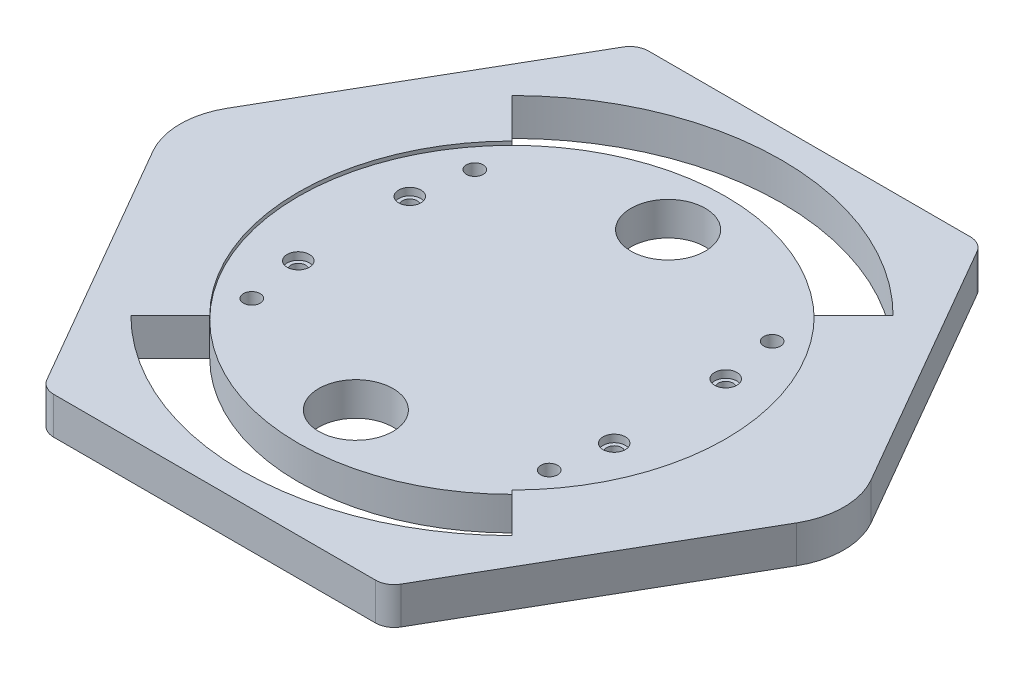
from build123d import *

# Parameters (mm, degrees)
BOSS_EXTRUDE1_DEPTH = 10
SKETCH8_R           = 2
CUT_EXTRUDE10_DEPTH = 21
SKETCH10_R          = 3
CUT_EXTRUDE11_DEPTH = 3
SKETCH11_R          = 2.25
CUT_EXTRUDE12_DEPTH = 12
SKETCH20_R          = 2.25
SKETCH20_R_2        = 3
CUT_EXTRUDE20_DEPTH = 1
CUT_EXTRUDE23_DEPTH = 153
SKETCH27_R          = 10
CUT_EXTRUDE24_DEPTH = 153
FILLET8_R           = 20
FILLET9_R           = 5


with BuildPart() as part:
    # Sketch1 → Boss-Extrude1 (new body)
    with BuildSketch(Plane(origin=(0, 0, 0), x_dir=(1, 0, 0), z_dir=(0, 1, 0))):
        Polygon((92.37604307, 0), (46.188021535, 80), (-46.188021535, 80), (-92.37604307, 0), (-46.188021535, -80), (46.188021535, -80), align=None)
    extrude(amount=BOSS_EXTRUDE1_DEPTH)

    # Sketch8 → Cut-Extrude10 (cut)
    with BuildSketch(Plane(origin=(0, 10, 0), x_dir=(1, 0, 0), z_dir=(0, 1, 0))):
        with Locations((-42.5, 15)):
            Circle(SKETCH8_R)
        with Locations((-42.5, -15)):
            Circle(SKETCH8_R)
        with Locations((42.5, 15)):
            Circle(SKETCH8_R)
        with Locations((42.5, -15)):
            Circle(SKETCH8_R)
    extrude(amount=-CUT_EXTRUDE10_DEPTH, mode=Mode.SUBTRACT)

    # Sketch10 → Cut-Extrude11 (cut)
    with BuildSketch(Plane(origin=(0, 10, 0), x_dir=(1, 0, 0), z_dir=(0, 1, 0))):
        with Locations((-42.5, 15)):
            Circle(SKETCH10_R)
        with Locations((-42.5, -15)):
            Circle(SKETCH10_R)
        with Locations((42.5, 15)):
            Circle(SKETCH10_R)
        with Locations((42.5, -15)):
            Circle(SKETCH10_R)
    extrude(amount=-CUT_EXTRUDE11_DEPTH, mode=Mode.SUBTRACT)

    # Sketch11 → Cut-Extrude12 (cut)
    with BuildSketch(Plane(origin=(0, 10, 0), x_dir=(1, 0, 0), z_dir=(0, 1, 0))):
        with Locations((-40, 30)):
            Circle(SKETCH11_R)
        with Locations((-40, -30)):
            Circle(SKETCH11_R)
        with Locations((40, -30)):
            Circle(SKETCH11_R)
        with Locations((40, 30)):
            Circle(SKETCH11_R)
    extrude(amount=-CUT_EXTRUDE12_DEPTH, mode=Mode.SUBTRACT)

    # Sketch20 → Cut-Extrude20 (cut)
    with BuildSketch(Plane(origin=(0, 10, 0), x_dir=(1, 0, 0), z_dir=(0, 1, 0))):
        with BuildLine():
            ThreePointArc((40.658639918, 40.658639918), (0, 57.5), (-40.658639918, 40.658639918))
            ThreePointArc((-40.658639918, 40.658639918), (-57.5, 0), (-40.658639918, -40.658639918))
            ThreePointArc((-40.658639918, -40.658639918), (0, -57.5), (40.658639918, -40.658639918))
            ThreePointArc((40.658639918, -40.658639918), (53.123073119, -22.004297361), (57.5, 0))
            ThreePointArc((57.5, 0), (53.123073119, 22.004297361), (40.658639918, 40.658639918))
        make_face()
        with Locations((-40, -30)):
            Circle(SKETCH20_R, mode=Mode.SUBTRACT)
        with Locations((-42.5, -15)):
            Circle(SKETCH20_R_2, mode=Mode.SUBTRACT)
        with Locations((40, -30)):
            Circle(SKETCH20_R, mode=Mode.SUBTRACT)
        with Locations((42.5, -15)):
            Circle(SKETCH20_R_2, mode=Mode.SUBTRACT)
        with Locations((-42.5, 15)):
            Circle(SKETCH20_R_2, mode=Mode.SUBTRACT)
        with Locations((-40, 30)):
            Circle(SKETCH20_R, mode=Mode.SUBTRACT)
        with Locations((42.5, 15)):
            Circle(SKETCH20_R_2, mode=Mode.SUBTRACT)
        with Locations((40, 30)):
            Circle(SKETCH20_R, mode=Mode.SUBTRACT)
    extrude(amount=-CUT_EXTRUDE20_DEPTH, mode=Mode.SUBTRACT)

    # Sketch20_7 → Cut-Extrude23 (cut)
    with BuildSketch(Plane(origin=(0, 10, 0), x_dir=(1, 0, 0), z_dir=(0, 1, 0))):
        with BuildLine():
            Line((-51.265241636, 51.265241636), (-40.658639918, 40.658639918))
            ThreePointArc((-40.658639918, 40.658639918), (0, 57.5), (40.658639918, 40.658639918))
            Line((40.658639918, 40.658639918), (51.265241636, 51.265241636))
            ThreePointArc((51.265241636, 51.265241636), (0, 72.5), (-51.265241636, 51.265241636))
        make_face()
        with BuildLine():
            ThreePointArc((40.658639918, -40.658639918), (0, -57.5), (-40.658639918, -40.658639918))
            Line((-40.658639918, -40.658639918), (-51.265241636, -51.265241636))
            ThreePointArc((-51.265241636, -51.265241636), (0, -72.5), (51.265241636, -51.265241636))
            Line((51.265241636, -51.265241636), (40.658639918, -40.658639918))
        make_face()
    extrude(amount=-CUT_EXTRUDE23_DEPTH, mode=Mode.SUBTRACT)

    # Sketch27 → Cut-Extrude24 (cut)
    with BuildSketch(Plane(origin=(0, 9, 0), x_dir=(1, 0, 0), z_dir=(0, 1, 0))):
        with Locations((0, -42)):
            Circle(SKETCH27_R)
        with Locations((0, 42)):
            Circle(SKETCH27_R)
    extrude(amount=-CUT_EXTRUDE24_DEPTH, mode=Mode.SUBTRACT)

    # Fillet8
    fillet8_edges = [part.edges().sort_by_distance(p)[0] for p in [
        (-92.37604307, 5, 0),
        (92.37604307, 5, 0),
    ]]
    fillet(fillet8_edges, radius=FILLET8_R)

    # Fillet9
    fillet9_edges = [part.edges().sort_by_distance(p)[0] for p in [
        (-46.188021535, 5, 80),
        (46.188021535, 5, 80),
        (-46.188021535, 5, -80),
        (46.188021535, 5, -80),
    ]]
    fillet(fillet9_edges, radius=FILLET9_R)


solid = part.part
